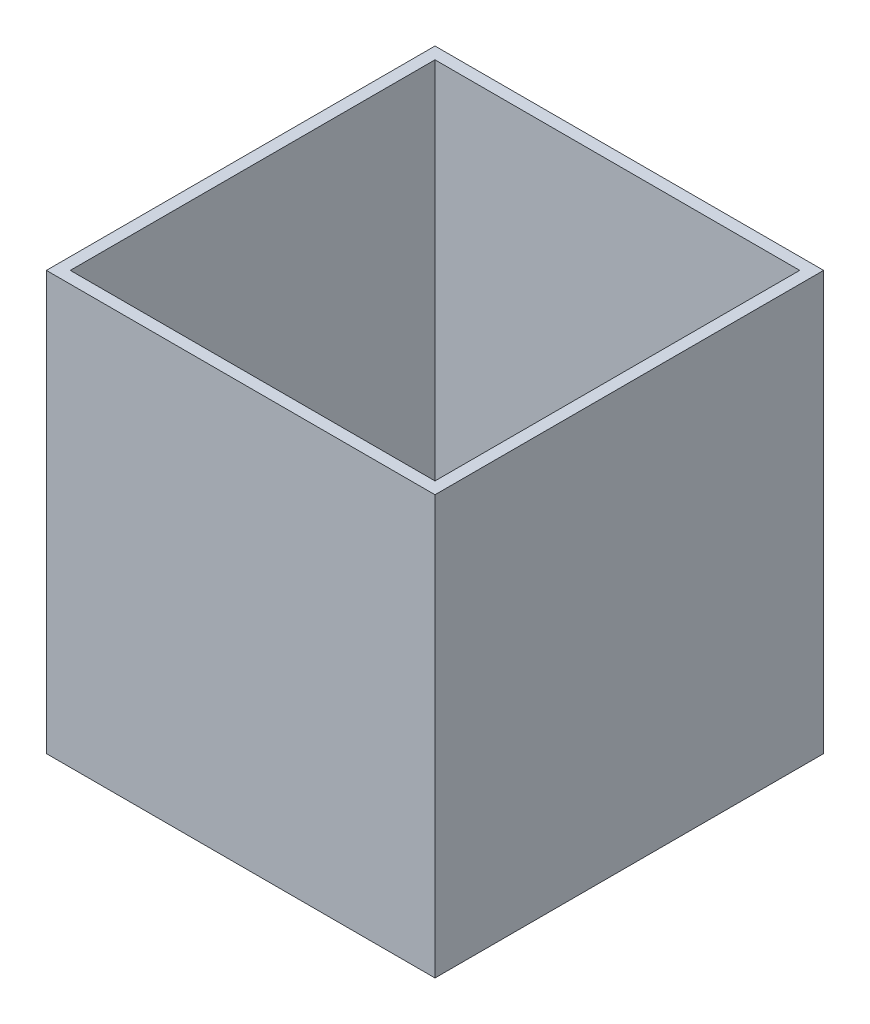
from build123d import *

# Parameters (mm, degrees)
SKETCH1_W           = 82.55
SKETCH1_H           = 82.55
BOSS_EXTRUDE1_DEPTH = 88.9
SHELL1_T            = -2.54


with BuildPart() as part:
    # Sketch1 → Boss-Extrude1 (new body)
    with BuildSketch(Plane(origin=(0, 0, 0), x_dir=(1, 0, 0), z_dir=(0, 1, 0))):
        with Locations((41.275, -41.275)):
            Rectangle(SKETCH1_W, SKETCH1_H)
    extrude(amount=BOSS_EXTRUDE1_DEPTH)

    # Shell1
    shell1_openings = [part.faces().sort_by_distance(p)[0] for p in [
        (41.275, 88.9, 41.275),
    ]]
    offset(amount=SHELL1_T, openings=shell1_openings, kind=Kind.INTERSECTION)


solid = part.part
